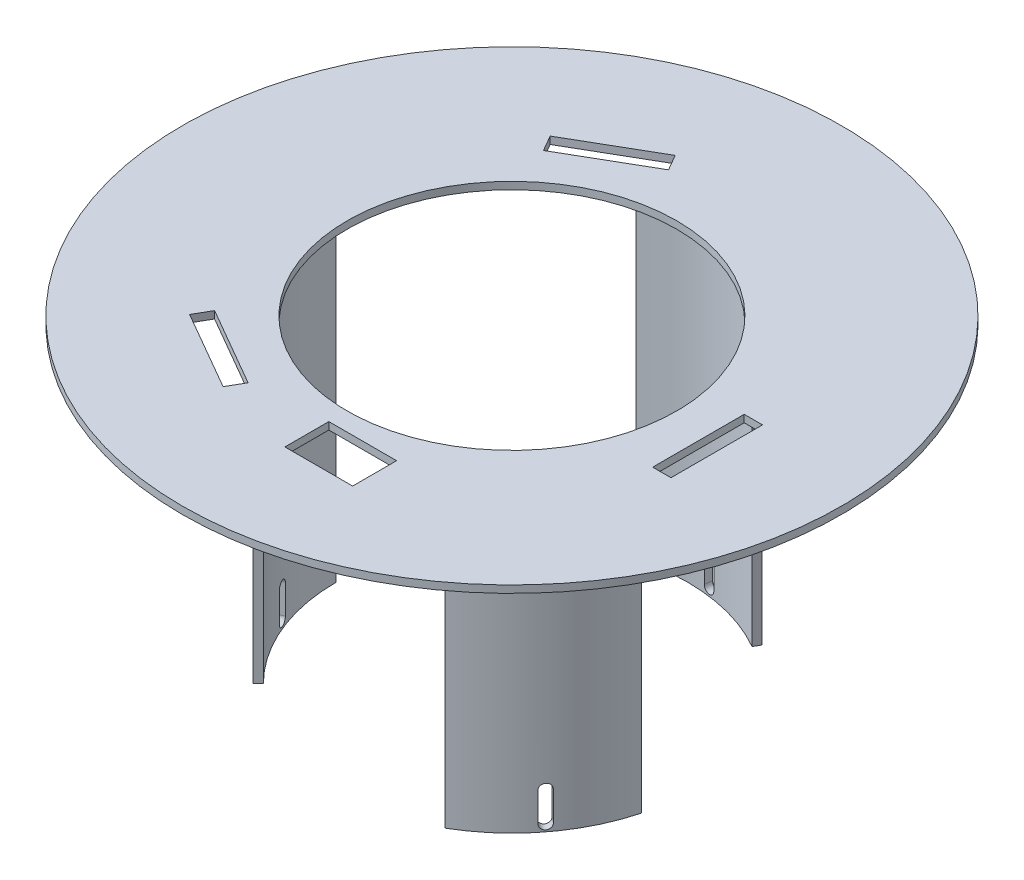
from build123d import *

# Parameters (mm, degrees)
SKETCH3_R           = 90
BOSS_EXTRUDE3_DEPTH = 2
SKETCH4_R           = 45
CUT_EXTRUDE1_DEPTH  = 2
BOSS_EXTRUDE4_DEPTH = 85
BOSS_EXTRUDE5_DEPTH = 85
CUT_EXTRUDE9_DEPTH  = 10
CIRPATTERN4_COUNT   = 3
CUT_EXTRUDE5_DEPTH  = 60
SKETCH15_W          = 5
SKETCH15_H          = 25
CUT_EXTRUDE10_DEPTH = 88.0000001
CIRPATTERN5_COUNT   = 3
SKETCH16_R          = 46
CUT_EXTRUDE11_DEPTH = 85
BOSS_EXTRUDE6_DEPTH = 2
SKETCH18_W          = 18.5
SKETCH18_H          = 12
CUT_EXTRUDE12_DEPTH = 2


with BuildPart() as part:
    # Sketch3 → Boss-Extrude3 (new body)
    with BuildSketch(Plane(origin=(0, 0, 0), x_dir=(1, 0, 0), z_dir=(0, 1, 0))):
        Circle(SKETCH3_R)
    extrude(amount=BOSS_EXTRUDE3_DEPTH)

    # Sketch4 → Cut-Extrude1 (cut)
    with BuildSketch(Plane.XZ):
        Circle(SKETCH4_R)
    extrude(amount=-CUT_EXTRUDE1_DEPTH, mode=Mode.SUBTRACT)

    # Sketch6 → Boss-Extrude4 (add)
    with BuildSketch(Plane.XZ):
        with BuildLine():
            Line((-46, 0), (-45, 0))
            ThreePointArc((-45, 0), (-41.574578963, 17.220754456), (-31.819805153, 31.819805153))
            Line((-31.819805153, 31.819805153), (-32.526911935, 32.526911935))
            ThreePointArc((-32.526911935, 32.526911935), (-42.498458496, 17.603437889), (-46, 0))
        make_face()
    boss_extrude4 = extrude(amount=BOSS_EXTRUDE4_DEPTH)

    # Sketch6_3 → Boss-Extrude5 (add)
    with BuildSketch(Plane.XZ):
        with BuildLine():
            Line((-50, 0), (-48, 0))
            ThreePointArc((-48, 0), (-44.346217561, 18.368804754), (-33.941125497, 33.941125497))
            Line((-33.941125497, 33.941125497), (-35.355339059, 35.355339059))
            ThreePointArc((-35.355339059, 35.355339059), (-46.193976626, 19.134171618), (-50, 0))
        make_face()
    boss_extrude5 = extrude(amount=BOSS_EXTRUDE5_DEPTH)

    # Sketch14 → Cut-Extrude9 (cut)
    with BuildSketch(Plane(origin=(-38.409902577, 0, 15.909902577), x_dir=(-0.382683432, 0, -0.923879533), z_dir=(0.923879533, 0, -0.382683432))):
        with BuildLine():
            Line((1.5, -75), (1.5, -83))
            ThreePointArc((1.5, -83), (0, -84.5), (-1.5, -83))
            Line((-1.5, -83), (-1.5, -75))
            ThreePointArc((-1.5, -75), (0, -73.5), (1.5, -75))
        make_face()
    cut_extrude9 = extrude(amount=-CUT_EXTRUDE9_DEPTH, mode=Mode.SUBTRACT)

    # CirPattern4: Boss-Extrude4, Boss-Extrude5, Cut-Extrude9 ×3 about axis
    cirpattern4_axis = Axis((0, 0, 0), (0, 1, 0))
    for i in range(1, CIRPATTERN4_COUNT):
        add(boss_extrude4.rotate(cirpattern4_axis, i * 360 / CIRPATTERN4_COUNT))
        add(boss_extrude5.rotate(cirpattern4_axis, i * 360 / CIRPATTERN4_COUNT))
        add(cut_extrude9.rotate(cirpattern4_axis, i * 360 / CIRPATTERN4_COUNT), mode=Mode.SUBTRACT)

    # Sketch11 → Cut-Extrude5 (cut, symmetric)
    with BuildSketch(Plane.XZ):
        Polygon((-6.747570404, -52.479477871), (11.40662685, -48.919264104), (13.715954699, -60.69495962), (-4.438242555, -64.255173387), align=None)
    extrude(amount=CUT_EXTRUDE5_DEPTH, both=True, mode=Mode.SUBTRACT)

    # Sketch15 → Cut-Extrude10 (cut, through all)
    with BuildSketch(Plane(origin=(0, 2, 0), x_dir=(1, 0, 0), z_dir=(0, 1, 0))):
        with Locations((57.5, -4.067185812)):
            Rectangle(SKETCH15_W, SKETCH15_H)
    cut_extrude10 = extrude(amount=-CUT_EXTRUDE10_DEPTH, mode=Mode.SUBTRACT)

    # CirPattern5: Cut-Extrude10 ×3 about axis
    cirpattern5_axis = Axis((0, 0, 0), (0, 1, 0))
    for i in range(1, CIRPATTERN5_COUNT):
        add(cut_extrude10.rotate(cirpattern5_axis, i * 360 / CIRPATTERN5_COUNT), mode=Mode.SUBTRACT)

    # Sketch16 → Cut-Extrude11 (cut)
    with BuildSketch(Plane.XZ.offset(85)):
        Circle(SKETCH16_R)
    extrude(amount=-CUT_EXTRUDE11_DEPTH, mode=Mode.SUBTRACT)

    # Sketch17 → Boss-Extrude6 (add)
    with BuildSketch(Plane(origin=(0, 2, 0), x_dir=(1, 0, 0), z_dir=(0, 1, 0))):
        Polygon((13.715954699, 60.69495962), (-4.438242555, 64.255173387), (-6.747570404, 52.479477871), (11.40662685, 48.919264104), align=None)
    extrude(amount=-BOSS_EXTRUDE6_DEPTH)

    # Sketch18 → Cut-Extrude12 (cut)
    with BuildSketch(Plane(origin=(0, 2, 0), x_dir=(1, 0, 0), z_dir=(0, 1, 0))):
        with Locations((9.25, -56)):
            Rectangle(SKETCH18_W, SKETCH18_H)
    extrude(amount=-CUT_EXTRUDE12_DEPTH, mode=Mode.SUBTRACT)


solid = part.part
